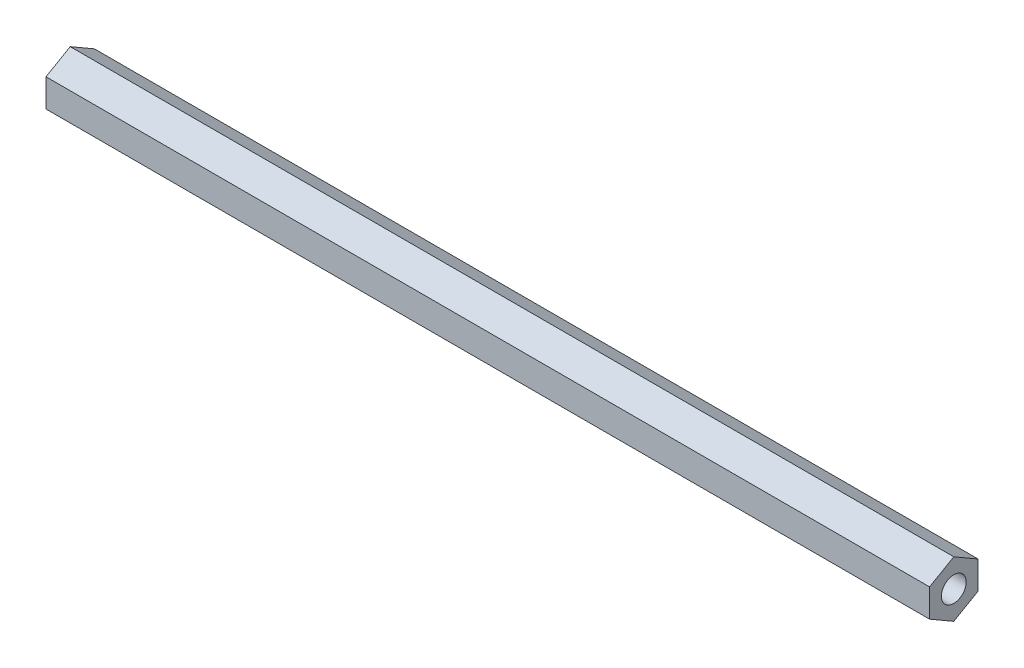
from build123d import *

# Parameters (mm, degrees)
BOSS_EXTRUDE1_DEPTH = 231.775
SKETCH2_R           = 3.2639
CUT_EXTRUDE1_DEPTH  = 12.7
SKETCH3_R           = 3.2639
CUT_EXTRUDE2_DEPTH  = 12.7


with BuildPart() as part:
    # Sketch1 → Boss-Extrude1 (new body)
    with BuildSketch(Plane(origin=(0, 0, 0), x_dir=(0, 0, -1), z_dir=(1, 0, 0))):
        Polygon((0, 7.332348419), (-6.35, 3.666174209), (-6.35, -3.666174209), (0, -7.332348419), (6.35, -3.666174209), (6.35, 3.666174209), align=None)
    extrude(amount=BOSS_EXTRUDE1_DEPTH)

    # Sketch2 → Cut-Extrude1 (cut)
    with BuildSketch(Plane(origin=(231.775, 0, 0), x_dir=(0, 0, -1), z_dir=(1, 0, 0))):
        Circle(SKETCH2_R)
    extrude(amount=-CUT_EXTRUDE1_DEPTH, mode=Mode.SUBTRACT)

    # Sketch3 → Cut-Extrude2 (cut)
    with BuildSketch(Plane.ZY):
        Circle(SKETCH3_R)
    extrude(amount=-CUT_EXTRUDE2_DEPTH, mode=Mode.SUBTRACT)


solid = part.part
